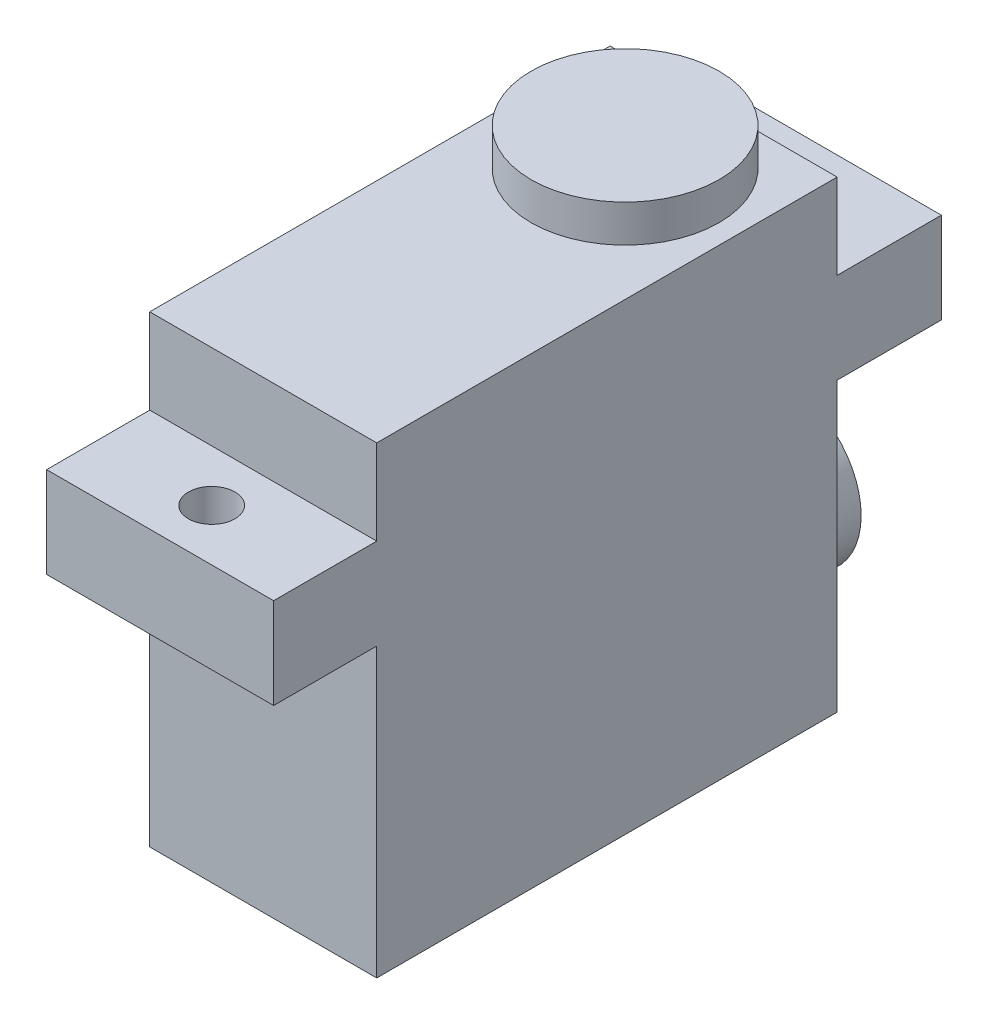
from build123d import *

# Parameters (mm, degrees)
SKETCH1_W                = 15.24
SKETCH1_H                = 30.9118
BOSS_EXTRUDE1_DEPTH      = 31.115
SKETCH2_W                = 15.24
SKETCH2_H                = 6.096
BOSS_EXTRUDE2_DEPTH      = 6.9215
BOSS_EXTRUDE2_DEPTH_BACK = 37.9095
SKETCH3_R                = 5.2705
BOSS_EXTRUDE3_DEPTH      = 3.9624
SKETCH4_R                = 6.3119
BOSS_EXTRUDE4_DEPTH      = 2.5019
CUT_EXTRUDE1_REACH       = 27.4
SKETCH8_R                = 1.5621
CUT_EXTRUDE2_REACH       = 27.4
SKETCH9_R                = 1.5621


with BuildPart() as part:
    # Sketch1 → Boss-Extrude1 (new body)
    with BuildSketch(Plane(origin=(0, 0, 0), x_dir=(1, 0, 0), z_dir=(0, 1, 0))):
        with Locations((7.62, 15.4559)):
            Rectangle(SKETCH1_W, SKETCH1_H)
    extrude(amount=BOSS_EXTRUDE1_DEPTH)

    # Sketch2 → Boss-Extrude2 (add, two sides)
    with BuildSketch(Plane.XY) as boss_extrude2_sk:
        with Locations((7.62, 22.352)):
            Rectangle(SKETCH2_W, SKETCH2_H)
    extrude(amount=BOSS_EXTRUDE2_DEPTH)
    extrude(boss_extrude2_sk.sketch, amount=-BOSS_EXTRUDE2_DEPTH_BACK)

    # Sketch3 → Boss-Extrude3 (add)
    with BuildSketch(Plane(origin=(0, 0, -30.9118), x_dir=(-1, 0, 0), z_dir=(0, 0, -1))):
        with Locations((-7.62, 8.2804)):
            Circle(SKETCH3_R)
    extrude(amount=BOSS_EXTRUDE3_DEPTH)

    # Sketch4 → Boss-Extrude4 (add)
    with BuildSketch(Plane(origin=(0, 31.115, 0), x_dir=(1, 0, 0), z_dir=(0, 1, 0))):
        with Locations((7.62, 24.2951)):
            Circle(SKETCH4_R)
    extrude(amount=BOSS_EXTRUDE4_DEPTH)

    # Sketch8 → Cut-Extrude1 (cut, up to next)
    with BuildSketch(Plane(origin=(0, 25.4, 0), x_dir=(1, 0, 0), z_dir=(0, 1, 0)), mode=Mode.PRIVATE) as cut_extrude1_sk1:
        with Locations((7.62, -3.46075)):
            Circle(SKETCH8_R)
    cut_extrude1_tool1 = extrude(cut_extrude1_sk1.sketch, amount=-CUT_EXTRUDE1_REACH, mode=Mode.PRIVATE) & part.part
    add(cut_extrude1_tool1.solids().sort_by_distance((7.62, 25.4, 3.46075))[0], mode=Mode.SUBTRACT)

    # Sketch9 → Cut-Extrude2 (cut, up to next)
    with BuildSketch(Plane(origin=(0, 25.4, 0), x_dir=(1, 0, 0), z_dir=(0, 1, 0)), mode=Mode.PRIVATE) as cut_extrude2_sk1:
        with Locations((7.62, 34.41065)):
            Circle(SKETCH9_R)
    cut_extrude2_tool1 = extrude(cut_extrude2_sk1.sketch, amount=-CUT_EXTRUDE2_REACH, mode=Mode.PRIVATE) & part.part
    add(cut_extrude2_tool1.solids().sort_by_distance((7.62, 25.4, -34.41065))[0], mode=Mode.SUBTRACT)


solid = part.part
